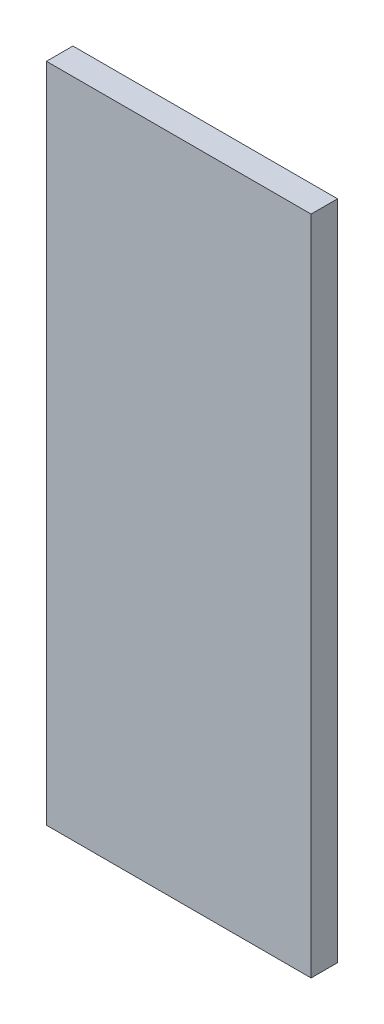
from build123d import *

# Parameters (mm, degrees)
SKETCH_1_W      = 20
SKETCH_1_H      = 2
EXTRUDE_1_DEPTH = 50


with BuildPart() as part:
    # Эскиз1 → Бобышка-Вытянуть1 (new body)
    with BuildSketch(Plane(origin=(0, 0, 0), x_dir=(1, 0, 0), z_dir=(0, 1, 0))):
        with Locations((10, 1)):
            Rectangle(SKETCH_1_W, SKETCH_1_H)
    extrude(amount=EXTRUDE_1_DEPTH)


solid = part.part
